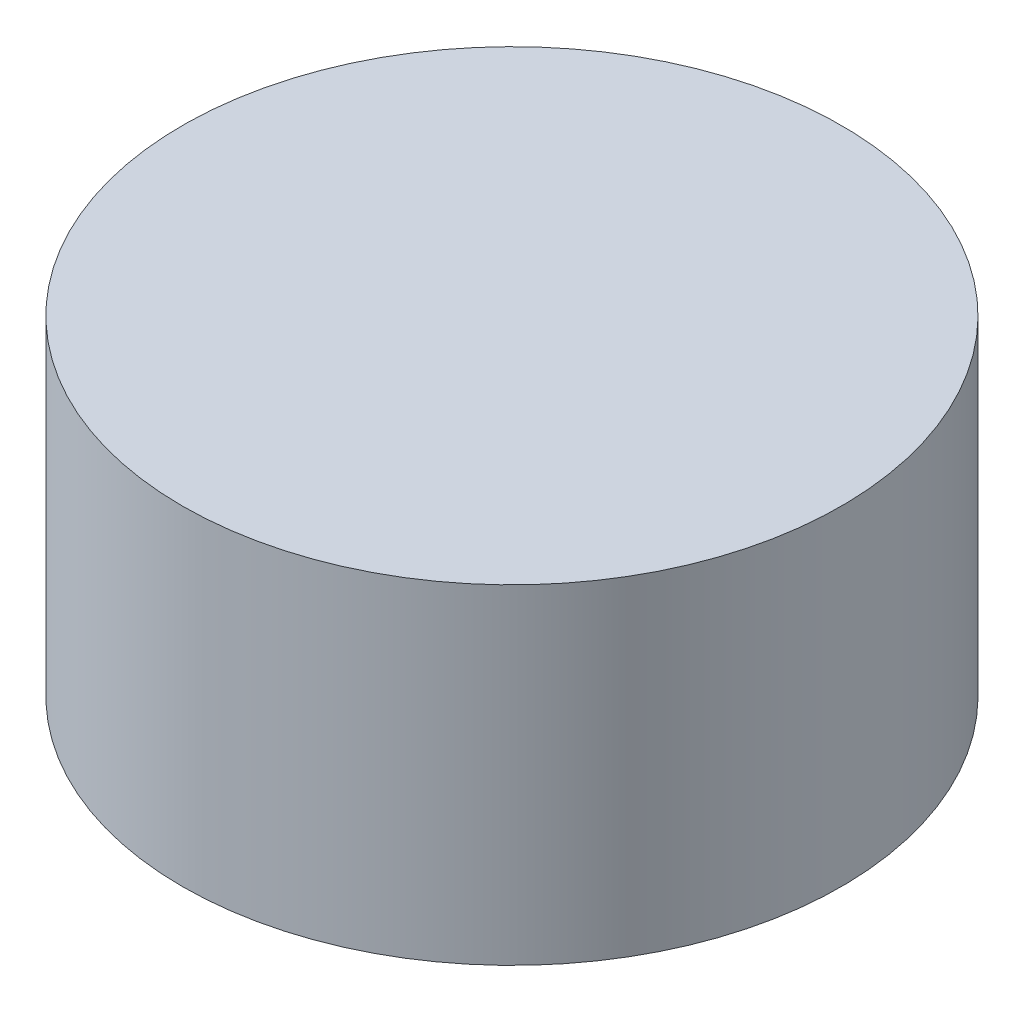
from build123d import *

# Parameters (mm, degrees)
SKETCH1_R           = 5
BOSS_EXTRUDE1_DEPTH = 5


with BuildPart() as part:
    # Sketch1 → Boss-Extrude1 (new body)
    with BuildSketch(Plane(origin=(0, 0, 0), x_dir=(1, 0, 0), z_dir=(0, 1, 0))):
        Circle(SKETCH1_R)
    extrude(amount=BOSS_EXTRUDE1_DEPTH)


solid = part.part
